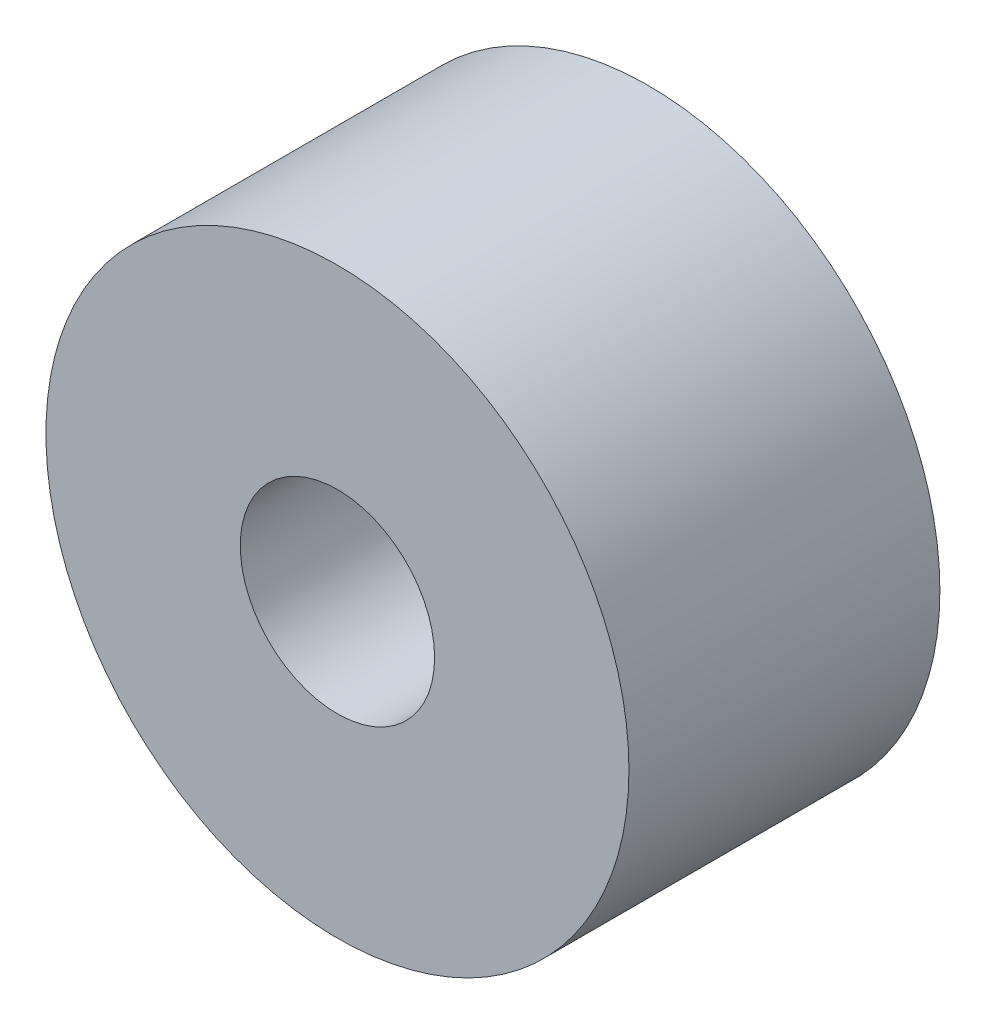
from build123d import *

# Parameters (mm, degrees)
SKETCH1_R           = 15
BOSS_EXTRUDE1_DEPTH = 16
SKETCH2_R           = 5
CUT_EXTRUDE1_DEPTH  = 16


with BuildPart() as part:
    # Sketch1 → Boss-Extrude1 (new body)
    with BuildSketch(Plane.XY):
        Circle(SKETCH1_R)
    extrude(amount=BOSS_EXTRUDE1_DEPTH)

    # Sketch2 → Cut-Extrude1 (cut)
    with BuildSketch(Plane.XY.offset(16)):
        Circle(SKETCH2_R)
    extrude(amount=-CUT_EXTRUDE1_DEPTH, mode=Mode.SUBTRACT)


solid = part.part
